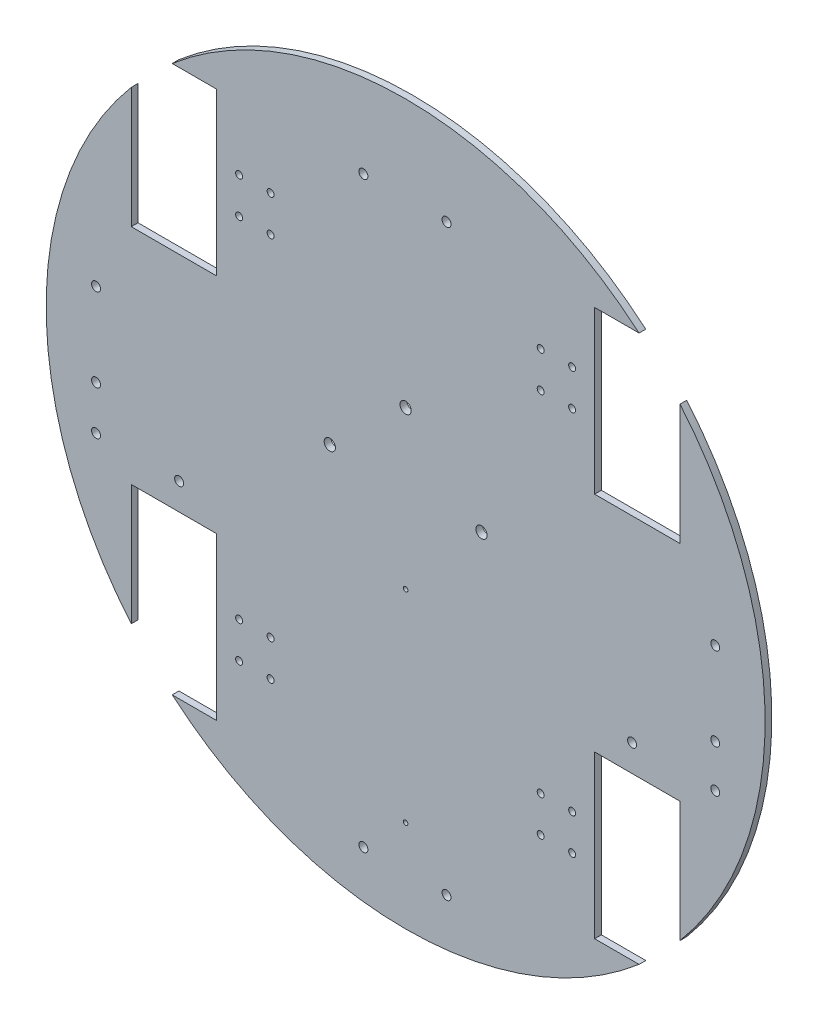
from build123d import *

# Parameters (mm, degrees)
SKETCH_1_R      = 2
SKETCH_1_R_2    = 1.55
SKETCH_1_R_3    = 1
SKETCH_1_R_4    = 2.5
EXTRUDE_1_DEPTH = 3


with BuildPart() as part:
    # 草图1 → 凸台-拉伸1 (new body)
    with BuildSketch(Plane.XY):
        with BuildLine():
            Line((-122.112109879, -103.385843426), (-122.112109879, -49.674836124))
            Line((-122.112109879, -49.674836124), (-84.112109879, -49.674836124))
            Line((-84.112109879, -49.674836124), (-84.112109879, -121.674836124))
            Line((-84.112109879, -121.674836124), (-103.900116719, -121.674836124))
            ThreePointArc((-103.900116719, -121.674836124), (0, -160), (103.900116719, -121.674836124))
            Line((103.900116719, -121.674836124), (84.112109879, -121.674836124))
            Line((84.112109879, -121.674836124), (84.112109879, -49.674836124))
            Line((84.112109879, -49.674836124), (122.112109879, -49.674836124))
            Line((122.112109879, -49.674836124), (122.112109879, -103.385843426))
            ThreePointArc((122.112109879, -103.385843426), (160, 0), (122.112109879, 103.385843426))
            Line((122.112109879, 103.385843426), (122.112109879, 49.674836124))
            Line((122.112109879, 49.674836124), (84.112109879, 49.674836124))
            Line((84.112109879, 49.674836124), (84.112109879, 121.674836124))
            Line((84.112109879, 121.674836124), (103.900116719, 121.674836124))
            ThreePointArc((103.900116719, 121.674836124), (0, 160), (-103.900116719, 121.674836124))
            Line((-103.900116719, 121.674836124), (-84.112109879, 121.674836124))
            Line((-84.112109879, 121.674836124), (-84.112109879, 49.674836124))
            Line((-84.112109879, 49.674836124), (-122.112109879, 49.674836124))
            Line((-122.112109879, 49.674836124), (-122.112109879, 103.385843426))
            ThreePointArc((-122.112109879, 103.385843426), (-160, 0), (-122.112109879, -103.385843426))
        make_face()
        with Locations((137.799674336, 18.195823561)):
            Circle(SKETCH_1_R, mode=Mode.SUBTRACT)
        with Locations((137.799674336, -18.804176439)):
            Circle(SKETCH_1_R, mode=Mode.SUBTRACT)
        with Locations((18.195823561, -137.799674336)):
            Circle(SKETCH_1_R, mode=Mode.SUBTRACT)
        with Locations((-18.804176439, -137.799674336)):
            Circle(SKETCH_1_R, mode=Mode.SUBTRACT)
        with Locations((-137.799674336, -18.195823561)):
            Circle(SKETCH_1_R, mode=Mode.SUBTRACT)
        with Locations((-137.799674336, 18.804176439)):
            Circle(SKETCH_1_R, mode=Mode.SUBTRACT)
        with Locations((-60.112109879, 93.674836124)):
            Circle(SKETCH_1_R_2, mode=Mode.SUBTRACT)
        with Locations((-60.112109879, 77.674836124)):
            Circle(SKETCH_1_R_2, mode=Mode.SUBTRACT)
        with Locations((-74.112109879, 93.674836124)):
            Circle(SKETCH_1_R_2, mode=Mode.SUBTRACT)
        with Locations((-74.112109879, 77.674836124)):
            Circle(SKETCH_1_R_2, mode=Mode.SUBTRACT)
        with Locations((0, -119)):
            Circle(SKETCH_1_R_3, mode=Mode.SUBTRACT)
        with Locations((0, -29)):
            Circle(SKETCH_1_R_3, mode=Mode.SUBTRACT)
        with Locations((-33.75, 9.85)):
            Circle(SKETCH_1_R_4, mode=Mode.SUBTRACT)
        with Locations((33.75, 9.85)):
            Circle(SKETCH_1_R_4, mode=Mode.SUBTRACT)
        with Locations((0, 41)):
            Circle(SKETCH_1_R_4, mode=Mode.SUBTRACT)
        with Locations((100.799676449, -37.721885932)):
            Circle(SKETCH_1_R, mode=Mode.SUBTRACT)
        with Locations((137.799674336, -37.734390952)):
            Circle(SKETCH_1_R, mode=Mode.SUBTRACT)
        with Locations((-137.799674336, -37.734390952)):
            Circle(SKETCH_1_R, mode=Mode.SUBTRACT)
        with Locations((-100.799676449, -37.721885932)):
            Circle(SKETCH_1_R, mode=Mode.SUBTRACT)
        with Locations((-18.804176439, 121.674836124)):
            Circle(SKETCH_1_R, mode=Mode.SUBTRACT)
        with Locations((18.195823561, 121.674836124)):
            Circle(SKETCH_1_R, mode=Mode.SUBTRACT)
        with Locations((74.112109879, 77.674836124)):
            Circle(SKETCH_1_R_2, mode=Mode.SUBTRACT)
        with Locations((74.112109879, 93.674836124)):
            Circle(SKETCH_1_R_2, mode=Mode.SUBTRACT)
        with Locations((60.112109879, 77.674836124)):
            Circle(SKETCH_1_R_2, mode=Mode.SUBTRACT)
        with Locations((60.112109879, 93.674836124)):
            Circle(SKETCH_1_R_2, mode=Mode.SUBTRACT)
        with Locations((60.112109879, -93.674836124)):
            Circle(SKETCH_1_R_2, mode=Mode.SUBTRACT)
        with Locations((60.112109879, -77.674836124)):
            Circle(SKETCH_1_R_2, mode=Mode.SUBTRACT)
        with Locations((74.112109879, -93.674836124)):
            Circle(SKETCH_1_R_2, mode=Mode.SUBTRACT)
        with Locations((74.112109879, -77.674836124)):
            Circle(SKETCH_1_R_2, mode=Mode.SUBTRACT)
        with Locations((-74.112109879, -77.674836124)):
            Circle(SKETCH_1_R_2, mode=Mode.SUBTRACT)
        with Locations((-74.112109879, -93.674836124)):
            Circle(SKETCH_1_R_2, mode=Mode.SUBTRACT)
        with Locations((-60.112109879, -77.674836124)):
            Circle(SKETCH_1_R_2, mode=Mode.SUBTRACT)
        with Locations((-60.112109879, -93.674836124)):
            Circle(SKETCH_1_R_2, mode=Mode.SUBTRACT)
    extrude(amount=EXTRUDE_1_DEPTH)


solid = part.part
